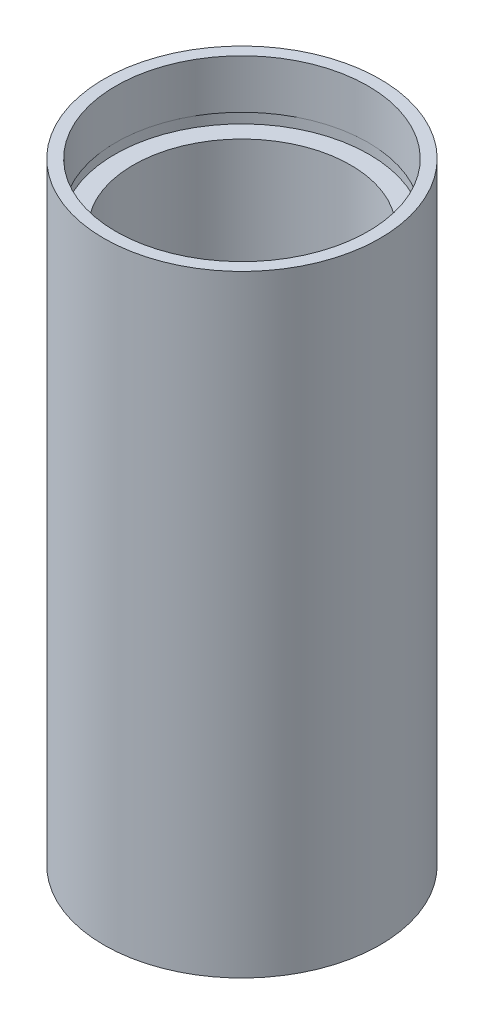
from build123d import *


with BuildPart() as part:
    # 草图1 → 旋转1 (revolve)
    with BuildSketch(Plane.XY, mode=Mode.PRIVATE) as revolve_1_sk:
        Polygon((11.1, 0), (11.1, 4.5), (11.7, 4.5), (11.7, 5.5), (10, 5.5), (10, 50.8), (11.7, 50.8), (11.7, 51.8), (11.6, 51.8), (11.6, 56.3), (12.7, 56.3), (12.7, 0), align=None)
    revolve(revolve_1_sk.sketch.rotate(Axis((0, 161.376166943, 0), (0, -1, 0)), 90), axis=Axis((0, 161.376166943, 0), (0, -1, 0)))  # turned: the seam where the file's is


solid = part.part
